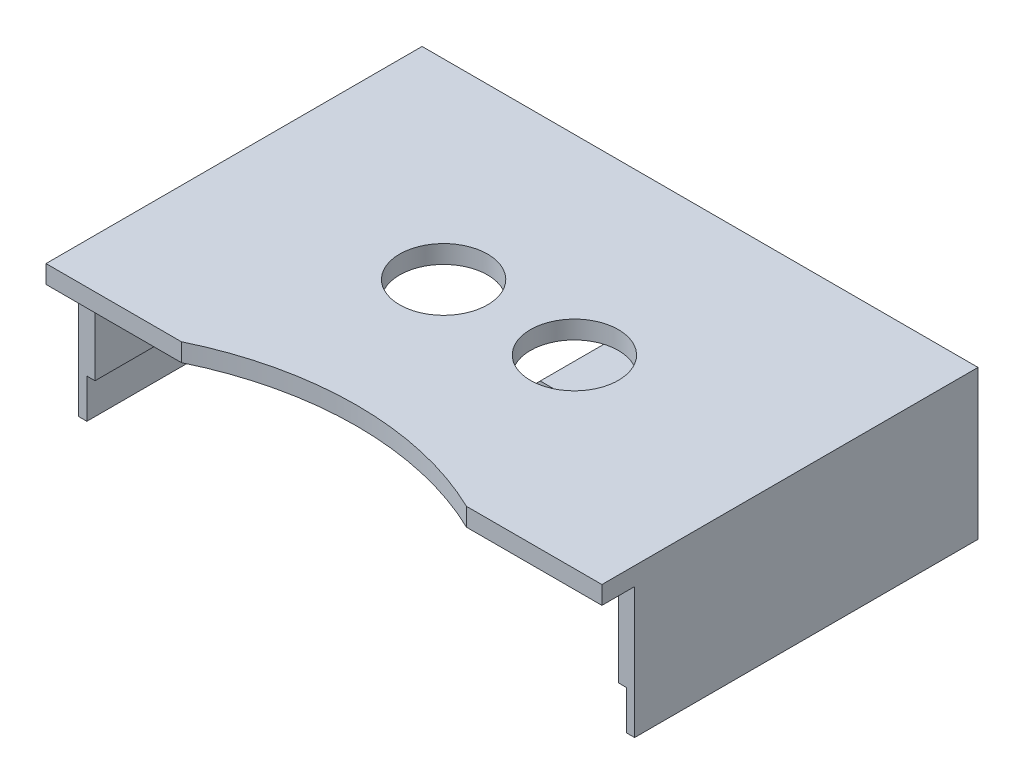
from build123d import *

# Parameters (mm, degrees)
BOSS_EXTRUDE1_DEPTH = 19.05
SKETCH2_W           = 17.018
SKETCH2_H           = 22.225
BOSS_EXTRUDE2_DEPTH = 3.175
SKETCH3_W           = 107.95
SKETCH3_H           = 3.513776003
BOSS_EXTRUDE3_DEPTH = 69.85
FILLET1_R           = 0.508
SKETCH4_R           = 8.54075
CUT_EXTRUDE1_DEPTH  = 26.738776003
SKETCH8_R           = 63.5
CUT_EXTRUDE2_DEPTH  = 26.738776003
SKETCH9_W           = 3.175
SKETCH9_H           = 28.913776003
BOSS_EXTRUDE4_DEPTH = 63.5
SKETCH10_W          = 107.95
SKETCH10_H          = 28.913776003
BOSS_EXTRUDE5_DEPTH = 3.175
SKETCH11_W          = 1.5875
SKETCH11_H          = 7.62
CUT_EXTRUDE3_DEPTH  = 63.5


with BuildPart() as part:
    # Sketch1 → Boss-Extrude1 (new body)
    with BuildSketch(Plane.XY):
        Polygon((8.80657951, 0), (-8.80657951, 0), (-11.98157951, -3.175), (11.98157951, -3.175), align=None)
    extrude(amount=BOSS_EXTRUDE1_DEPTH)

    # Sketch2 → Boss-Extrude2 (add)
    with BuildSketch(Plane(origin=(0, 0, 0), x_dir=(-1, 0, 0), z_dir=(0, 0, -1))):
        with Locations((0, 7.9375)):
            Rectangle(SKETCH2_W, SKETCH2_H)
    extrude(amount=-BOSS_EXTRUDE2_DEPTH)

    # Sketch3 → Boss-Extrude3 (add)
    with BuildSketch(Plane(origin=(0, 0, 0), x_dir=(-1, 0, 0), z_dir=(0, 0, -1))):
        with Locations((0, 20.806888001)):
            Rectangle(SKETCH3_W, SKETCH3_H)
    extrude(amount=-BOSS_EXTRUDE3_DEPTH)

    # Fillet1
    fillet1_edges = [part.edges().sort_by_distance(p)[0] for p in [
        (11.98157951, -3.175, 9.525),
        (-11.98157951, -3.175, 9.525),
    ]]
    fillet(fillet1_edges, radius=FILLET1_R)

    # Sketch4 → Cut-Extrude1 (cut, through all)
    with BuildSketch(Plane(origin=(0, 22.563776003, 0), x_dir=(1, 0, 0), z_dir=(0, 1, 0))):
        with Locations((12.7, -33.9190628)):
            Circle(SKETCH4_R)
        with Locations((-12.7, -33.9190628)):
            Circle(SKETCH4_R)
    extrude(amount=-CUT_EXTRUDE1_DEPTH, mode=Mode.SUBTRACT)

    # Sketch8 → Cut-Extrude2 (cut, through all)
    with BuildSketch(Plane(origin=(0, 22.563776003, 0), x_dir=(1, 0, 0), z_dir=(0, 1, 0))):
        with Locations((0, -127)):
            Circle(SKETCH8_R)
    extrude(amount=-CUT_EXTRUDE2_DEPTH, mode=Mode.SUBTRACT)

    # Sketch9 → Boss-Extrude4 (add)
    with BuildSketch(Plane(origin=(0, 0, 0), x_dir=(-1, 0, 0), z_dir=(0, 0, -1))):
        with Locations((52.3875, 8.106888001)):
            Rectangle(SKETCH9_W, SKETCH9_H)
        with Locations((-52.3875, 8.106888001)):
            Rectangle(SKETCH9_W, SKETCH9_H)
    extrude(amount=-BOSS_EXTRUDE4_DEPTH)

    # Sketch10 → Boss-Extrude5 (add)
    with BuildSketch(Plane(origin=(0, 0, 0), x_dir=(-1, 0, 0), z_dir=(0, 0, -1))):
        with Locations((0, 8.106888001)):
            Rectangle(SKETCH10_W, SKETCH10_H)
    extrude(amount=BOSS_EXTRUDE5_DEPTH)

    # Sketch11 → Cut-Extrude3 (cut)
    with BuildSketch(Plane.XY.offset(63.5)):
        with Locations((51.59375, -2.54)):
            Rectangle(SKETCH11_W, SKETCH11_H)
        with Locations((-51.59375, -2.54)):
            Rectangle(SKETCH11_W, SKETCH11_H)
    extrude(amount=-CUT_EXTRUDE3_DEPTH, mode=Mode.SUBTRACT)


solid = part.part
